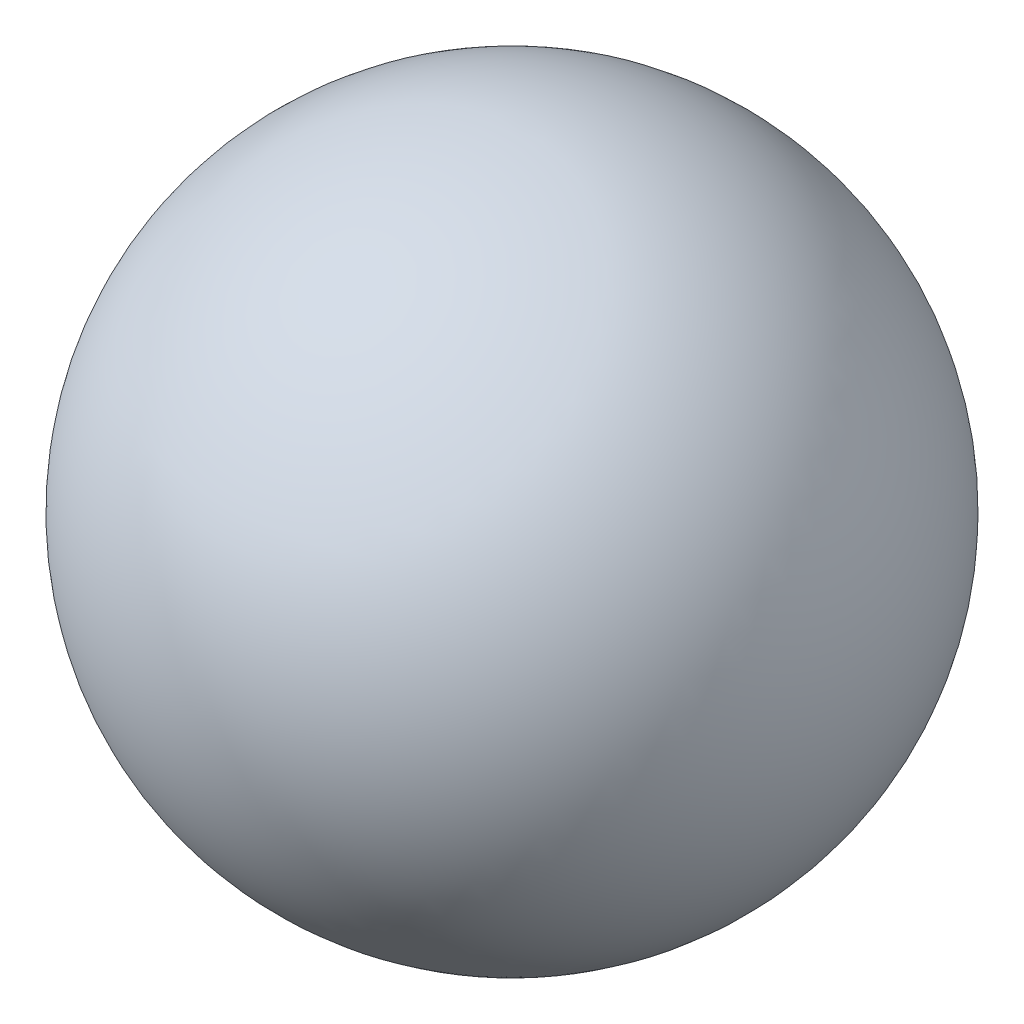
from build123d import *

# Parameters (mm, degrees)
M4_CLEARANCE_HOLE1_D     = 4.5
M4_CLEARANCE_HOLE1_DEPTH = 7.5
M4_CLEARANCE_HOLE1_TIP   = 1.351936393


with BuildPart() as part:
    # Sketch1 → Revolve3 (revolve)
    with BuildSketch(Plane.XY):
        with BuildLine():
            Line((0, -5), (0, 5))
            ThreePointArc((0, 5), (5, 0), (0, -5))
        make_face()
    revolve(axis=Axis((0, -5, 0), (0, 1, 0)))

    # M4 Clearance Hole1
    with Locations(Plane(origin=(0, -5, 0), x_dir=(-1, 0, 0), z_dir=(0, -1, 0))):
        with Locations((0, 0)):
            Hole(M4_CLEARANCE_HOLE1_D / 2, depth=M4_CLEARANCE_HOLE1_DEPTH)
            with Locations((0, 0, -(M4_CLEARANCE_HOLE1_DEPTH + M4_CLEARANCE_HOLE1_TIP / 2))):  # 118° drill point
                Cone(0, M4_CLEARANCE_HOLE1_D / 2, M4_CLEARANCE_HOLE1_TIP, mode=Mode.SUBTRACT)


solid = part.part
